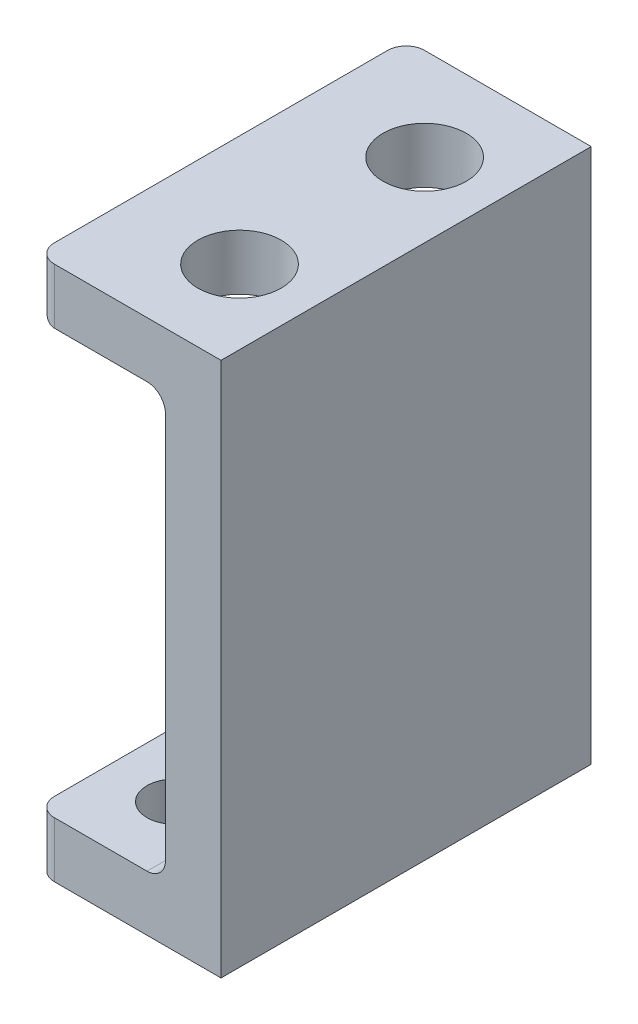
from build123d import *

# Parameters (mm, degrees)
BOSS_EXTRUDE1_DEPTH = 20
SKETCH2_R           = 2.25
CUT_EXTRUDE1_DEPTH  = 20
SKETCH3_R           = 1.5
CUT_EXTRUDE2_DEPTH  = 20
FILLET1_R           = 1
FILLET2_R           = 1


with BuildPart() as part:
    # Sketch1 → Boss-Extrude1 (new body)
    with BuildSketch(Plane.XY):
        Polygon((0, -10.581899729), (0, 12.318100271), (-7, 12.318100271), (-7, 15.318100271), (3, 15.318100271), (3, -13.581899729), (-7, -13.581899729), (-7, -10.581899729), align=None)
    extrude(amount=BOSS_EXTRUDE1_DEPTH)

    # Sketch2 → Cut-Extrude1 (cut)
    with BuildSketch(Plane(origin=(0, 15.318100271, 0), x_dir=(1, 0, 0), z_dir=(0, 1, 0))):
        with Locations((-1, -5)):
            Circle(SKETCH2_R)
        with Locations((-1, -15)):
            Circle(SKETCH2_R)
    extrude(amount=-CUT_EXTRUDE1_DEPTH, mode=Mode.SUBTRACT)

    # Sketch3 → Cut-Extrude2 (cut)
    with BuildSketch(Plane(origin=(0, -10.581899729, 0), x_dir=(1, 0, 0), z_dir=(0, 1, 0))):
        with Locations((-3.5, -4)):
            Circle(SKETCH3_R)
        with Locations((-3.5, -10)):
            Circle(SKETCH3_R)
        with Locations((-3.5, -16)):
            Circle(SKETCH3_R)
    extrude(amount=-CUT_EXTRUDE2_DEPTH, mode=Mode.SUBTRACT)

    # Fillet1
    fillet1_edges = [part.edges().sort_by_distance(p)[0] for p in [
        (-7, -12.081899729, 0),
        (0, -10.581899729, 10),
        (-7, 12.318100271, 10),
        (-7, 13.818100271, 20),
        (-7, -12.081899729, 20),
        (-7, 13.818100271, 0),
    ]]
    fillet(fillet1_edges, radius=FILLET1_R)

    # Fillet2
    fillet2_edges = [part.edges().sort_by_distance(p)[0] for p in [
        (0, 12.318100271, 18.507782219),
        (0, 12.318100271, 10),
        (0, 12.318100271, 1.492217781),
    ]]
    fillet(fillet2_edges, radius=FILLET2_R)


solid = part.part
